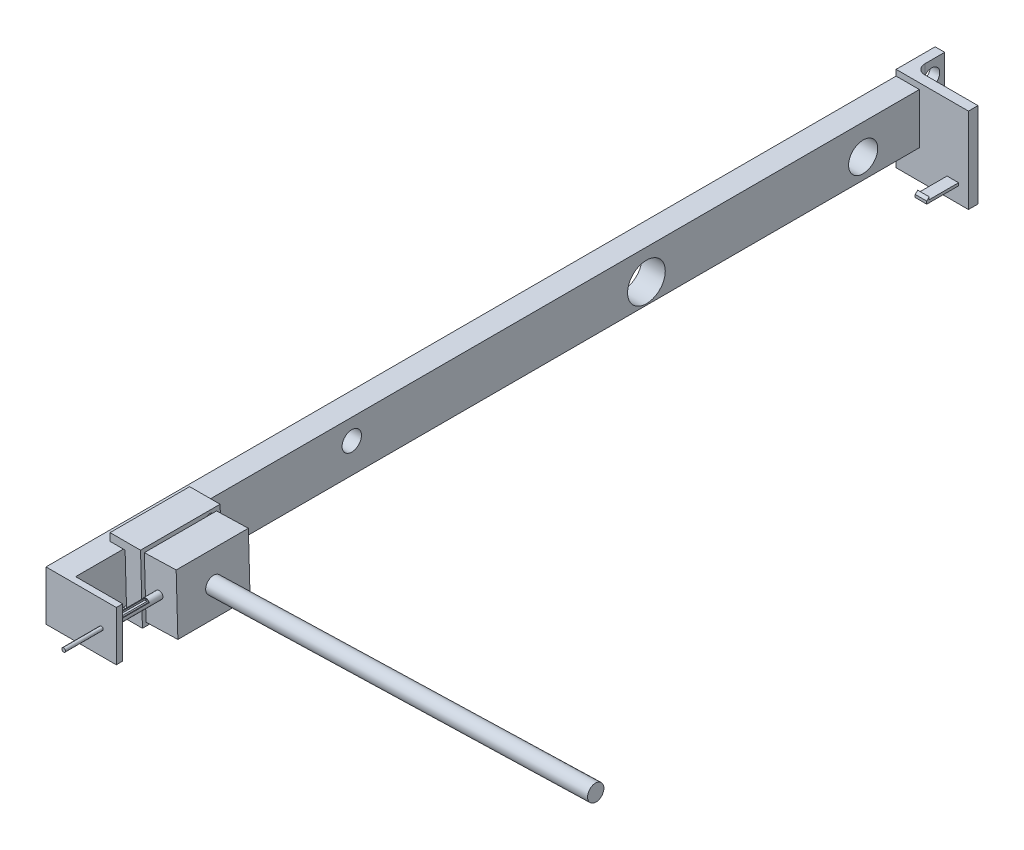
from build123d import *

# Parameters (mm, degrees)
SKETCH1_W            = 7.305999503
SKETCH1_H            = 15.829665589
BOSS_EXTRUDE1_DEPTH  = 250
SKETCH2_R            = 2.859737651
SKETCH2_R_2          = 3.043630703
SKETCH2_R_3          = 5.918472751
SKETCH2_R_4          = 4.573365308
CUT_EXTRUDE1_DEPTH   = 250
BOSS_EXTRUDE2_DEPTH  = 25
SKETCH4_R            = 0.55626985
SKETCH4_R_2          = 0.971483528
SKETCH4_R_3          = 0.995085758
SKETCH4_R_4          = 0.977672137
CUT_EXTRUDE2_DEPTH   = 2
SKETCH5_W            = 22.677292764
SKETCH5_H            = 18.650483769
BOSS_EXTRUDE3_DEPTH  = 10
SKETCH7_W            = 7.305999503
SKETCH7_H            = 15.829665589
BOSS_EXTRUDE4_DEPTH  = 15
SKETCH8_R            = 0.583511753
BOSS_EXTRUDE5_DEPTH  = 30
SKETCH10_R           = 1.176105539
SKETCH10_R_2         = 0.991111504
BOSS_EXTRUDE6_DEPTH  = 16.164956
SKETCH11_W           = 22.072449834
SKETCH11_H           = 15.598961577
SKETCH11_R           = 0.583511753
BOSS_EXTRUDE7_DEPTH  = 2
SKETCH12_W           = 8.462475972
SKETCH12_H           = 0.708060972
CUT_EXTRUDE3_DEPTH   = 16.949179392
SKETCH13_R           = 2.558098884
BOSS_EXTRUDE8_DEPTH  = 120
SKETCH14_W           = 4.036675172
SKETCH14_H           = 2.530453093
CUT_EXTRUDE4_DEPTH   = 3
SKETCH15_W           = 22.723161813
SKETCH15_H           = 26.77895865
BOSS_EXTRUDE9_DEPTH  = 3
SKETCH16_W           = 3.62280941
SKETCH16_H           = 0.845659338
BOSS_EXTRUDE10_DEPTH = 10
BOSS_EXTRUDE11_DEPTH = 3.622809
SKETCH20_W           = 9.26545532
SKETCH20_H           = 26.77895865
SKETCH20_R           = 2.555213065
SKETCH20_R_2         = 1.645957428
BOSS_EXTRUDE12_DEPTH = 3
FILLET1_R            = 3


with BuildPart() as part:
    # Sketch1 → Boss-Extrude1 (new body)
    with BuildSketch(Plane.XY):
        with Locations((3.652999752, 7.914832795)):
            Rectangle(SKETCH1_W, SKETCH1_H)
    extrude(amount=BOSS_EXTRUDE1_DEPTH)

    # Sketch2 → Cut-Extrude1 (cut)
    with BuildSketch(Plane(origin=(7.305999503, 0, 0), x_dir=(0, 0, -1), z_dir=(1, 0, 0))):
        with Locations((-228.573273141, 9.394450982)):
            Circle(SKETCH2_R)
        with Locations((-178.266254758, 9.394450982)):
            Circle(SKETCH2_R_2)
        with Locations((-85.722862653, 6.350820279)):
            Circle(SKETCH2_R_3)
        with Locations((-17.660426017, 6.350820279)):
            Circle(SKETCH2_R_4)
    extrude(amount=-CUT_EXTRUDE1_DEPTH, mode=Mode.SUBTRACT)

    # Sketch3 → Boss-Extrude2 (add)
    with BuildSketch(Plane.XY.offset(250)):
        Polygon((3.119708773, 18.218776332), (3.119708773, 15.829665589), (7.843143149, 15.829665589), (8.300249701, 0), (3.119708773, 0), (3.119708773, -2.731940657), (13.290329566, -2.731940657), (12.68534458, 18.218776332), align=None)
    extrude(amount=-BOSS_EXTRUDE2_DEPTH)

    # Sketch4 → Cut-Extrude2 (cut)
    with BuildSketch(Plane(origin=(13.200433203, 0.381183322, 0), x_dir=(0, 0, -1), z_dir=(0.999583332, 0.028864545, 0))):
        with Locations((-247.357123666, 16.004078596)):
            Circle(SKETCH4_R)
        with Locations((-228.271108715, 16.004078596)):
            Circle(SKETCH4_R_2)
        with Locations((-228.271108715, -0.707178735)):
            Circle(SKETCH4_R_3)
        with Locations((-246.800853817, -0.707178735)):
            Circle(SKETCH4_R_4)
    extrude(amount=-CUT_EXTRUDE2_DEPTH, mode=Mode.SUBTRACT)

    # Sketch5 → Boss-Extrude3 (add)
    with BuildSketch(Plane(origin=(13.200433203, 0.381183322, 0), x_dir=(0, 0, -1), z_dir=(0.999583332, 0.028864545, 0))):
        with Locations((-237.496397387, 7.284247631)):
            Rectangle(SKETCH5_W, SKETCH5_H)
    extrude(amount=BOSS_EXTRUDE3_DEPTH)

    # Sketch7 → Boss-Extrude4 (add)
    with BuildSketch(Plane.XY.offset(250)):
        with Locations((3.652999752, 7.914832795)):
            Rectangle(SKETCH7_W, SKETCH7_H)
    extrude(amount=BOSS_EXTRUDE4_DEPTH)

    # Sketch8 → Boss-Extrude5 (add)
    with BuildSketch(Plane.XY.offset(248.835043769)):
        with Locations((17.375180219, 7.845532394)):
            Circle(SKETCH8_R)
    extrude(amount=BOSS_EXTRUDE5_DEPTH)

    # Sketch10 → Boss-Extrude6 (add)
    with BuildSketch(Plane.XY.offset(248.835043769)):
        with Locations((17.375180219, 7.845532394)):
            Circle(SKETCH10_R)
        with Locations((17.375180219, 7.845532394)):
            Circle(SKETCH10_R_2, mode=Mode.SUBTRACT)
    extrude(amount=BOSS_EXTRUDE6_DEPTH)

    # Sketch11 → Boss-Extrude7 (add)
    with BuildSketch(Plane.XY.offset(265)):
        with Locations((11.036224917, 8.030184801)):
            Rectangle(SKETCH11_W, SKETCH11_H)
        with Locations((17.375180219, 7.845532394)):
            Circle(SKETCH11_R, mode=Mode.SUBTRACT)
    extrude(amount=BOSS_EXTRUDE7_DEPTH)

    # Sketch12 → Cut-Extrude3 (cut, through all)
    with BuildSketch(Plane(origin=(7.305999503, 0, 0), x_dir=(0, 0, -1), z_dir=(1, 0, 0))):
        with Locations((-257.232117953, 8.667607447)):
            Rectangle(SKETCH12_W, SKETCH12_H)
    extrude(amount=CUT_EXTRUDE3_DEPTH, mode=Mode.SUBTRACT)

    # Sketch13 → Boss-Extrude8 (add)
    with BuildSketch(Plane(origin=(23.196266525, 0.669828769, 0), x_dir=(0, 0, -1), z_dir=(0.999583332, 0.028864545, 0))):
        with Locations((-237.28625307, 6.924561564)):
            Circle(SKETCH13_R)
    extrude(amount=BOSS_EXTRUDE8_DEPTH)

    # Sketch14 → Cut-Extrude4 (cut)
    with BuildSketch(Plane(origin=(0.05891237, -2.040143836, 0), x_dir=(0.999583332, 0.028864545, 0), z_dir=(0.028864545, -0.999583332, 0))):
        with Locations((18.81578383, 228.781338254)):
            Rectangle(SKETCH14_W, SKETCH14_H)
    extrude(amount=-CUT_EXTRUDE4_DEPTH, mode=Mode.SUBTRACT)

    # Sketch15 → Boss-Extrude9 (add)
    with BuildSketch(Plane(origin=(0, 0, 0), x_dir=(-1, 0, 0), z_dir=(0, 0, -1))):
        with Locations((-11.361580907, 4.28062146)):
            Rectangle(SKETCH15_W, SKETCH15_H)
    extrude(amount=BOSS_EXTRUDE9_DEPTH)

    # Sketch16 → Boss-Extrude10 (add)
    with BuildSketch(Plane.XY):
        with Locations((17.811006308, -3.783209828)):
            Rectangle(SKETCH16_W, SKETCH16_H)
    extrude(amount=BOSS_EXTRUDE10_DEPTH)

    # Sketch17 → Boss-Extrude11 (add)
    with BuildSketch(Plane(origin=(19.622411013, 0, 0), x_dir=(0, 0, -1), z_dir=(1, 0, 0))):
        Polygon((-10, -3.360380159), (-9.219259529, -2.579639689), (-9.219259529, -3.360380159), align=None)
    extrude(amount=-BOSS_EXTRUDE11_DEPTH)

    # Sketch20 → Boss-Extrude12 (add)
    with BuildSketch(Plane.ZY):
        with Locations((-7.63272766, 4.28062146)):
            Rectangle(SKETCH20_W, SKETCH20_H)
        with Locations((-8.150644595, 12.915896002)):
            Circle(SKETCH20_R, mode=Mode.SUBTRACT)
        with Locations((-7.163070138, -4.86044422)):
            Circle(SKETCH20_R_2, mode=Mode.SUBTRACT)
    extrude(amount=-BOSS_EXTRUDE12_DEPTH)

    # Fillet1
    fillet1_edges = [part.edges().sort_by_distance(p)[0] for p in [
        (3, 4.28062146, -3),
    ]]
    fillet(fillet1_edges, radius=FILLET1_R)


solid = part.part
